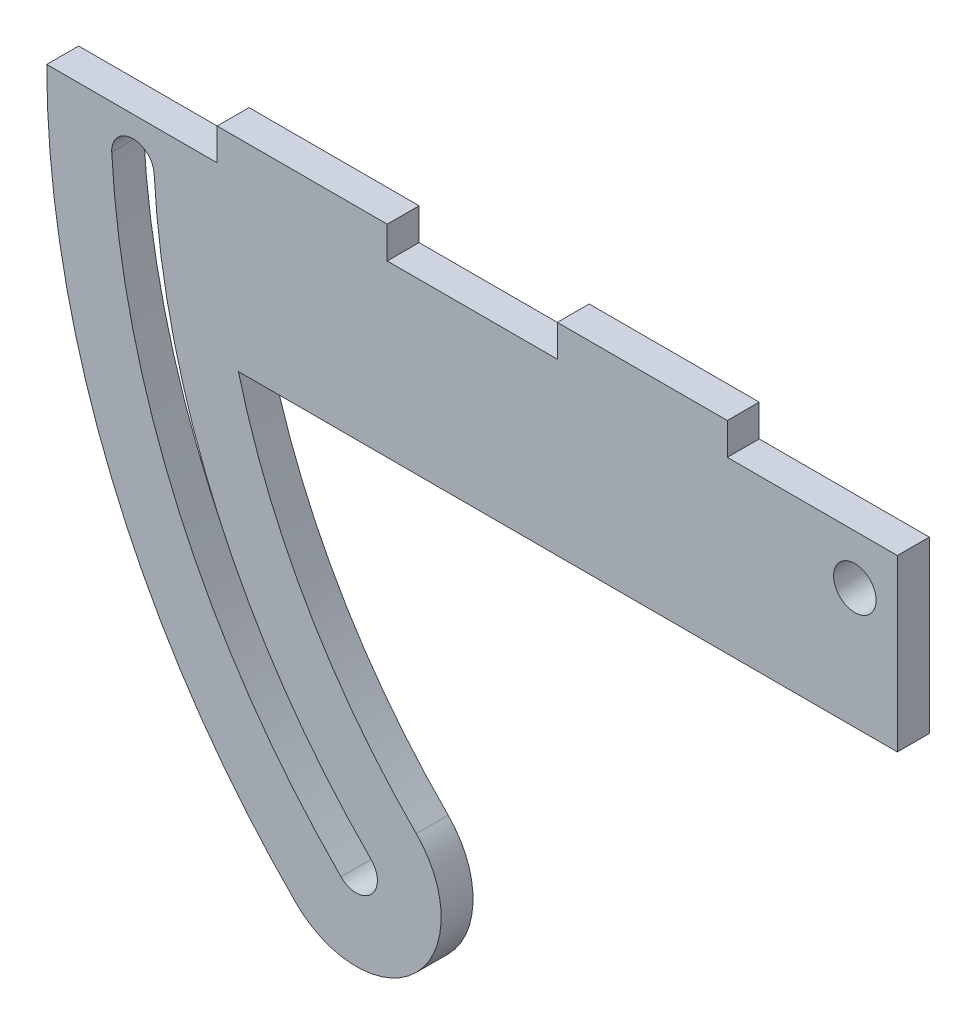
from build123d import *

# Parameters (mm, degrees)
SKETCH1_R           = 3.175
BOSS_EXTRUDE1_DEPTH = 4.7625


with BuildPart() as part:
    # Sketch1 → Boss-Extrude1 (new body)
    with BuildSketch(Plane.XY):
        with BuildLine():
            Line((50.8, 26.433162162), (76.2, 26.433162162))
            Line((76.2, 26.433162162), (76.2, 31.195662162))
            Line((76.2, 31.195662162), (101.6, 31.195662162))
            Line((101.6, 31.195662162), (101.6, 26.433162162))
            Line((101.6, 26.433162162), (127, 26.433162162))
            Line((127, 26.433162162), (127, 1.01998892))
            Line((127, 1.01998892), (28.57520326, 1.01998892))
            ThreePointArc((28.57520326, 1.01998892), (38.742465974, -24.003706053), (55.140964092, -45.46641326))
            ThreePointArc((55.140964092, -45.46641326), (55.140964092, -63.426925502), (37.180451849, -63.426925502))
            ThreePointArc((37.180451849, -63.426925502), (9.624103867, -22.201039712), (-0.05269216, 26.433162162))
            Line((-0.05269216, 26.433162162), (25.4, 26.433162162))
            Line((25.4, 26.433162162), (25.4, 31.195662162))
            Line((25.4, 31.195662162), (50.8, 31.195662162))
            Line((50.8, 31.195662162), (50.8, 26.433162162))
        make_face()
        with Locations((120.65, 19.05)):
            Circle(SKETCH1_R, mode=Mode.SUBTRACT)
        with BuildLine():
            ThreePointArc((15.995135135, 20.234189189), (12.675972973, 23.258162162), (9.652, 19.939))
            ThreePointArc((9.652, 19.939), (19.70325304, -21.526564047), (43.895465689, -56.671372149))
            ThreePointArc((43.895465689, -56.671372149), (48.405772001, -56.691733412), (48.385410738, -52.1814271))
            ThreePointArc((48.385410738, -52.1814271), (25.511627679, -18.960863581), (15.995135135, 20.234189189))
        make_face(mode=Mode.SUBTRACT)
    extrude(amount=BOSS_EXTRUDE1_DEPTH)


solid = part.part
